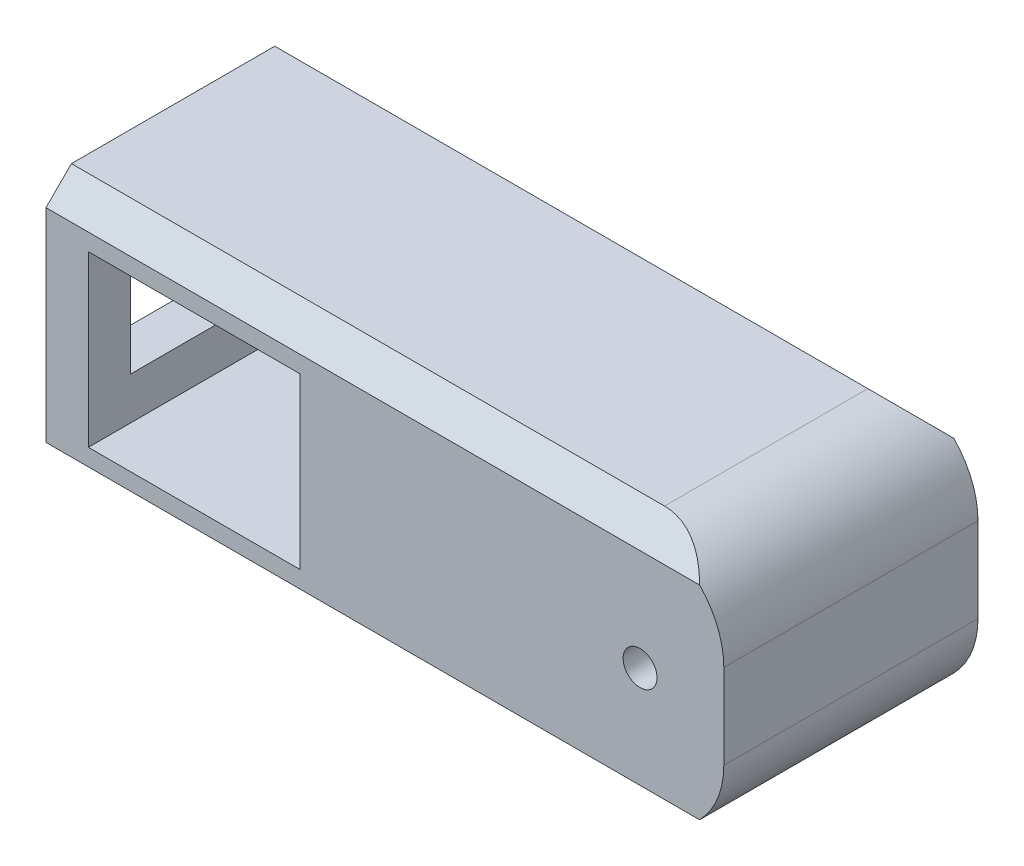
from build123d import *

# Parameters (mm, degrees)
SKETCH1_W           = 80
SKETCH1_H           = 30
BOSS_EXTRUDE1_DEPTH = 30
SKETCH2_R           = 2
CUT_EXTRUDE1_DEPTH  = 30
CHAMFER1_SIZE       = 3
SKETCH3_W           = 25
SKETCH3_H           = 20
CUT_EXTRUDE2_DEPTH  = 30
SKETCH4_W           = 20
SKETCH4_H           = 10
CUT_EXTRUDE3_DEPTH  = 20
FILLET1_R           = 10


with BuildPart() as part:
    # Sketch1 → Boss-Extrude1 (new body)
    with BuildSketch(Plane(origin=(0, 0, 0), x_dir=(1, 0, 0), z_dir=(0, 1, 0))):
        Rectangle(SKETCH1_W, SKETCH1_H)
    extrude(amount=BOSS_EXTRUDE1_DEPTH)

    # Sketch2 → Cut-Extrude1 (cut)
    with BuildSketch(Plane.XY.offset(15)):
        with Locations((30.11486463, 15)):
            Circle(SKETCH2_R)
    extrude(amount=-CUT_EXTRUDE1_DEPTH, mode=Mode.SUBTRACT)

    # Chamfer1
    chamfer1_edges = [part.edges().sort_by_distance(p)[0] for p in [
        (0, 30, 15),
        (0, 0, 15),
        (0, 0, -15),
        (0, 30, -15),
    ]]
    chamfer(chamfer1_edges, length=CHAMFER1_SIZE)

    # Sketch3 → Cut-Extrude2 (cut)
    with BuildSketch(Plane(origin=(0, 0, -15), x_dir=(-1, 0, 0), z_dir=(0, 0, -1))):
        with Locations((22.5, 15)):
            Rectangle(SKETCH3_W, SKETCH3_H)
    extrude(amount=-CUT_EXTRUDE2_DEPTH, mode=Mode.SUBTRACT)

    # Sketch4 → Cut-Extrude3 (cut)
    with BuildSketch(Plane.ZY.offset(40)):
        with Locations((0, 15)):
            Rectangle(SKETCH4_W, SKETCH4_H)
    extrude(amount=-CUT_EXTRUDE3_DEPTH, mode=Mode.SUBTRACT)

    # Fillet1
    fillet1_edges = [part.edges().sort_by_distance(p)[0] for p in [
        (40, 0, 0),
        (40, 30, 0),
    ]]
    fillet(fillet1_edges, radius=FILLET1_R)


solid = part.part
